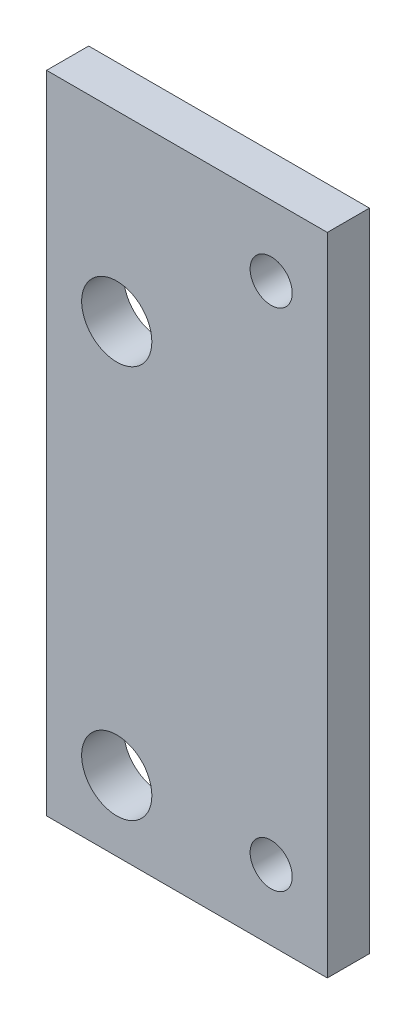
from build123d import *

# Parameters (mm, degrees)
ESQUISSE1_W      = 20
ESQUISSE1_H      = 46
ESQUISSE1_R      = 2.5
ESQUISSE1_R_2    = 1.5
EXTRUSION1_DEPTH = 3


with BuildPart() as part:
    # Esquisse1 → Extrusion1 (new body)
    with BuildSketch(Plane.XY):
        with Locations((10, 23)):
            Rectangle(ESQUISSE1_W, ESQUISSE1_H)
        with Locations((5, 33)):
            Circle(ESQUISSE1_R, mode=Mode.SUBTRACT)
        with Locations((5, 5)):
            Circle(ESQUISSE1_R, mode=Mode.SUBTRACT)
        with Locations((16, 41)):
            Circle(ESQUISSE1_R_2, mode=Mode.SUBTRACT)
        with Locations((16, 5)):
            Circle(ESQUISSE1_R_2, mode=Mode.SUBTRACT)
    extrude(amount=EXTRUSION1_DEPTH)


solid = part.part
